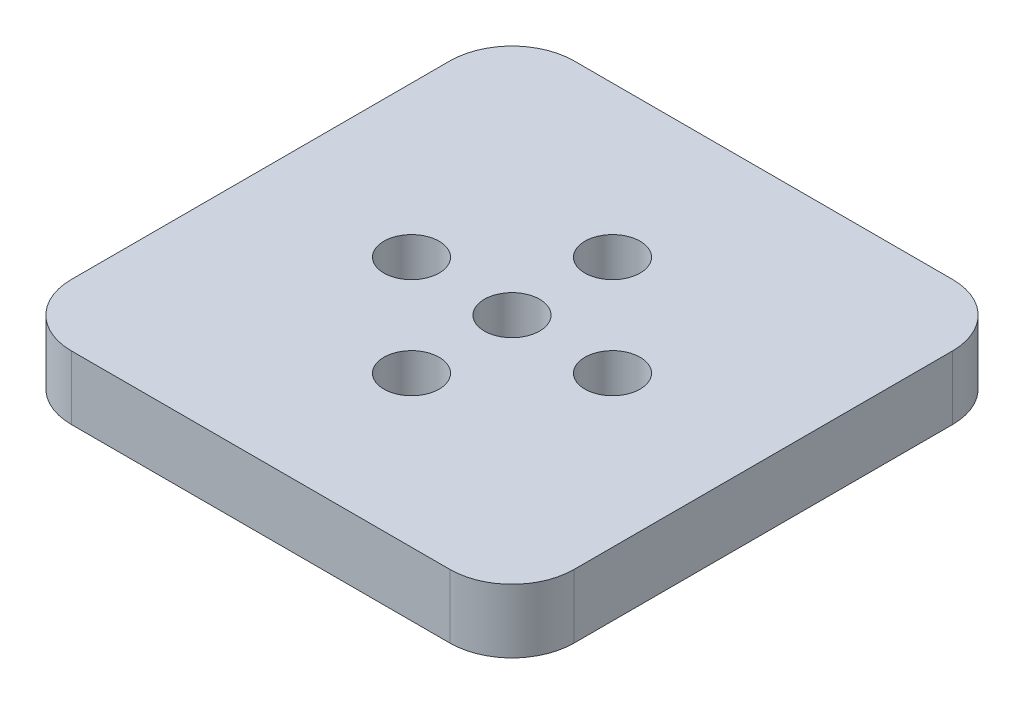
from build123d import *

# Parameters (mm, degrees)
EXTRUDE_1_DEPTH    = 6.35
HOLE_WIZARD_M5_1_D = 5.5


with BuildPart() as part:
    # 스케치1 → 보스-돌출1 (new body)
    with BuildSketch(Plane(origin=(0, 0, 0), x_dir=(1, 0, 0), z_dir=(0, 1, 0))):
        with BuildLine():
            Line((-18.83, 25), (18.83, 25))
            ThreePointArc((18.83, 25), (23.19284884, 23.19284884), (25, 18.83))
            Line((25, 18.83), (25, -18.83))
            ThreePointArc((25, -18.83), (23.19284884, -23.19284884), (18.83, -25))
            Line((18.83, -25), (-18.83, -25))
            ThreePointArc((-18.83, -25), (-23.19284884, -23.19284884), (-25, -18.83))
            Line((-25, -18.83), (-25, 18.83))
            ThreePointArc((-25, 18.83), (-23.19284884, 23.19284884), (-18.83, 25))
        make_face()
    extrude(amount=-EXTRUDE_1_DEPTH)

    # M5 여유 구멍1 (through all)
    with Locations(Plane(origin=(0, 0, 0), x_dir=(1, 0, 0), z_dir=(0, 1, 0))):
        with Locations((0, 10), (10, 0), (0, -10), (-10, 0), (0, 0)):
            Hole(HOLE_WIZARD_M5_1_D / 2)


solid = part.part
